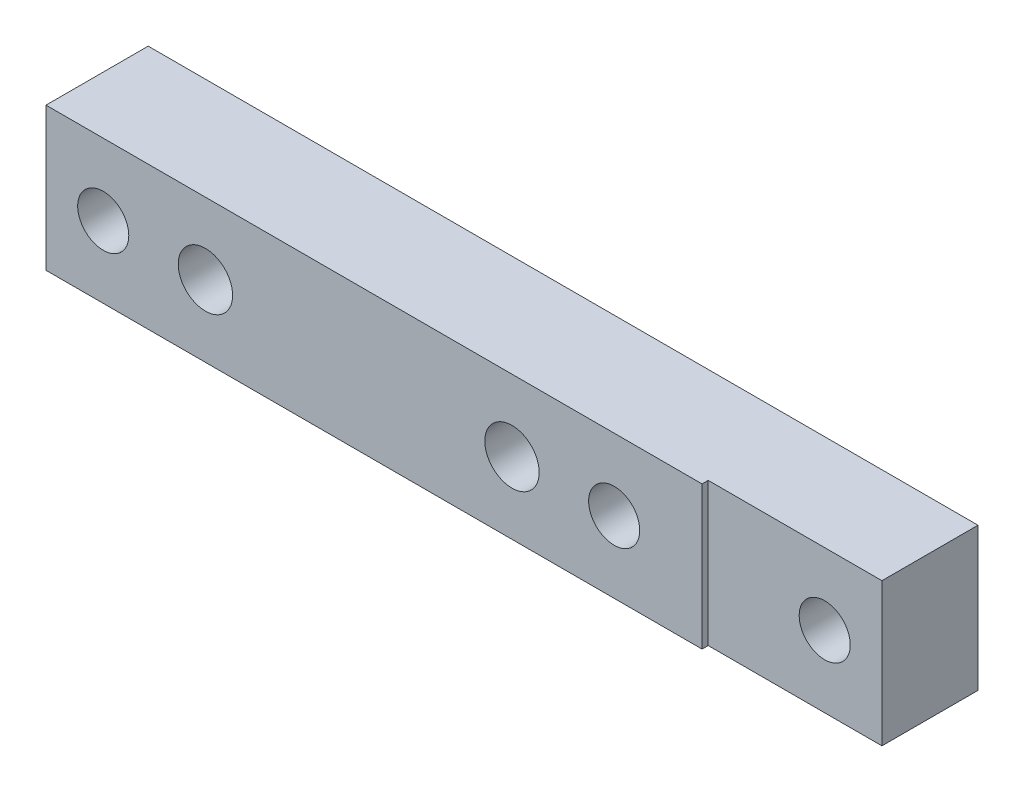
from build123d import *

# Parameters (mm, degrees)
SKETCH_R                    = 3.175
BOSS_EXTRUDE1_DEPTH         = 12.7
SKETCH3_W                   = 21.59
SKETCH3_H                   = 17.78
CUT_EXTRUDE1_DEPTH          = 0.762
F_1_4_CLEARANCE_HOLE1_D     = 6.7564
F_1_4_CLEARANCE_HOLE1_DEPTH = 12.7


with BuildPart() as part:
    # Sketch → Boss-Extrude1 (new body)
    with BuildSketch(Plane.XY):
        Polygon((-70.612, 8.89), (32.512, 8.89), (32.512, 0), (32.512, -8.89), (-70.612, -8.89), align=None)
        with Locations((-63.5, 0)):
            Circle(SKETCH_R, mode=Mode.SUBTRACT)
        Circle(SKETCH_R, mode=Mode.SUBTRACT)
        with Locations((25.4, 0)):
            Circle(SKETCH_R, mode=Mode.SUBTRACT)
    extrude(amount=-BOSS_EXTRUDE1_DEPTH)

    # Sketch3 → Cut-Extrude1 (cut)
    with BuildSketch(Plane(origin=(0, 0, 0), x_dir=(-1, 0, 0), z_dir=(0, 0, -1))):
        with Locations((-21.717, 0)):
            Rectangle(SKETCH3_W, SKETCH3_H)
    extrude(amount=CUT_EXTRUDE1_DEPTH, mode=Mode.SUBTRACT)

    # 1/4 Clearance Hole1
    with Locations(Plane.XY):
        with Locations((-50.8, 0), (-12.7, 0)):
            Hole(F_1_4_CLEARANCE_HOLE1_D / 2, depth=F_1_4_CLEARANCE_HOLE1_DEPTH)


solid = part.part
